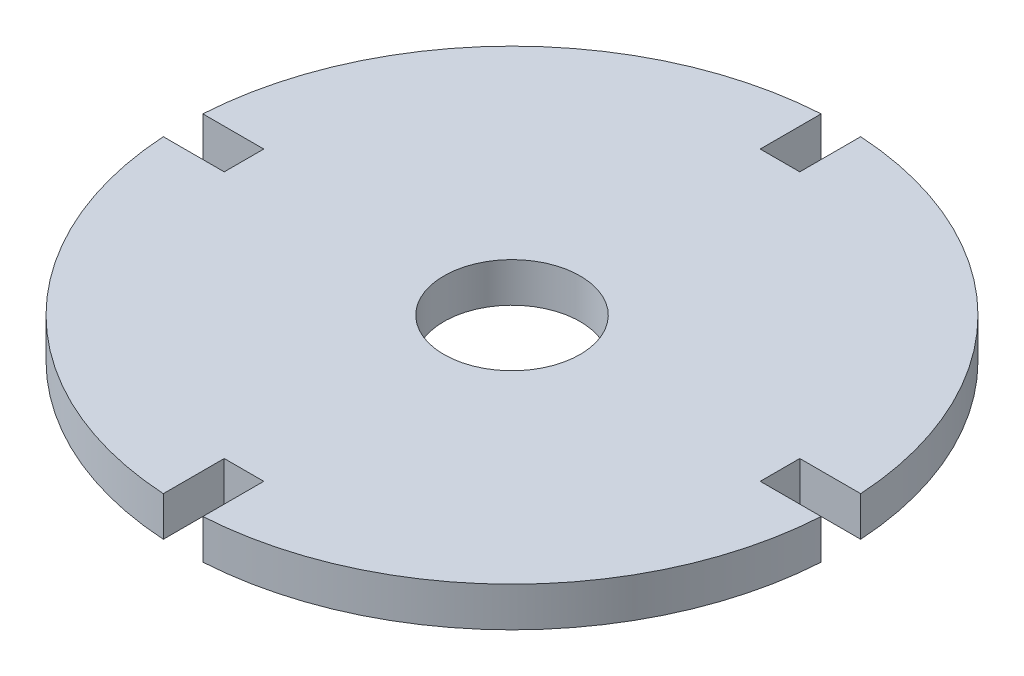
from build123d import *

# Parameters (mm, degrees)
ESBO_O3_R                = 75
ESBO_O3_R_2              = 15.5
RESSALTO_EXTRUS_O2_DEPTH = 9
CORTE_EXTRUS_O1_REACH    = 11


with BuildPart() as part:
    # Esboço3 → Ressalto-extrusão2 (new body)
    with BuildSketch(Plane(origin=(0, 0, 0), x_dir=(1, 0, 0), z_dir=(0, 1, 0))):
        with Locations(Location((0, 0, 0), (0, 0, 270))):  # turned: the seam where the file's is
            Circle(ESBO_O3_R)
        with Locations(Location((0, 0, 0), (0, 0, 270))):  # turned: the seam where the file's is
            Circle(ESBO_O3_R_2, mode=Mode.SUBTRACT)
    extrude(amount=RESSALTO_EXTRUS_O2_DEPTH)

    # Esboço5 → Corte-extrusão1 (cut, up to next)
    with BuildSketch(Plane(origin=(0, 9, 0), x_dir=(1, 0, 0), z_dir=(0, 1, 0)), mode=Mode.PRIVATE) as corte_extrus_o1_sk1:
        with BuildLine():
            ThreePointArc((0, 75), (-2.251014098, 74.966211959), (-4.5, 74.864878281))
            Line((-4.5, 74.864878281), (-4.5, 61))
            Line((-4.5, 61), (4.5, 61))
            Line((4.5, 61), (4.5, 74.864878281))
            ThreePointArc((4.5, 74.864878281), (2.251014098, 74.966211959), (0, 75))
        make_face()
    corte_extrus_o1_tool1 = extrude(corte_extrus_o1_sk1.sketch, amount=-CORTE_EXTRUS_O1_REACH, mode=Mode.PRIVATE) & part.part
    add(corte_extrus_o1_tool1.solids().sort_by_distance((0, 9, -67.977546))[0], mode=Mode.SUBTRACT)
    # Esboço5 → Corte-extrusão1 (cut, up to next)
    with BuildSketch(Plane(origin=(0, 9, 0), x_dir=(1, 0, 0), z_dir=(0, 1, 0)), mode=Mode.PRIVATE) as corte_extrus_o1_sk2:
        with BuildLine():
            Line((61, -4.5), (74.864878281, -4.5))
            ThreePointArc((74.864878281, -4.5), (74.966211959, -2.251014098), (75, 0))
            ThreePointArc((75, 0), (74.966211959, 2.251014098), (74.864878281, 4.5))
            Line((74.864878281, 4.5), (61, 4.5))
            Line((61, 4.5), (61, -4.5))
        make_face()
    corte_extrus_o1_tool2 = extrude(corte_extrus_o1_sk2.sketch, amount=-CORTE_EXTRUS_O1_REACH, mode=Mode.PRIVATE) & part.part
    add(corte_extrus_o1_tool2.solids().sort_by_distance((67.977546, 9, 0))[0], mode=Mode.SUBTRACT)
    # Esboço5 → Corte-extrusão1 (cut, up to next)
    with BuildSketch(Plane(origin=(0, 9, 0), x_dir=(1, 0, 0), z_dir=(0, 1, 0)), mode=Mode.PRIVATE) as corte_extrus_o1_sk3:
        with BuildLine():
            Line((-4.5, -61), (-4.5, -74.864878281))
            ThreePointArc((-4.5, -74.864878281), (-2.251014098, -74.966211959), (0, -75))
            ThreePointArc((0, -75), (2.251014098, -74.966211959), (4.5, -74.864878281))
            Line((4.5, -74.864878281), (4.5, -61))
            Line((4.5, -61), (-4.5, -61))
        make_face()
    corte_extrus_o1_tool3 = extrude(corte_extrus_o1_sk3.sketch, amount=-CORTE_EXTRUS_O1_REACH, mode=Mode.PRIVATE) & part.part
    add(corte_extrus_o1_tool3.solids().sort_by_distance((0, 9, 67.977546))[0], mode=Mode.SUBTRACT)
    # Esboço5 → Corte-extrusão1 (cut, up to next)
    with BuildSketch(Plane(origin=(0, 9, 0), x_dir=(1, 0, 0), z_dir=(0, 1, 0)), mode=Mode.PRIVATE) as corte_extrus_o1_sk4:
        with BuildLine():
            ThreePointArc((-75, 0), (-74.966211959, -2.251014098), (-74.864878281, -4.5))
            Line((-74.864878281, -4.5), (-61, -4.5))
            Line((-61, -4.5), (-61, 4.5))
            Line((-61, 4.5), (-74.864878281, 4.5))
            ThreePointArc((-74.864878281, 4.5), (-74.966211959, 2.251014098), (-75, 0))
        make_face()
    corte_extrus_o1_tool4 = extrude(corte_extrus_o1_sk4.sketch, amount=-CORTE_EXTRUS_O1_REACH, mode=Mode.PRIVATE) & part.part
    add(corte_extrus_o1_tool4.solids().sort_by_distance((-67.977546, 9, 0))[0], mode=Mode.SUBTRACT)


solid = part.part
